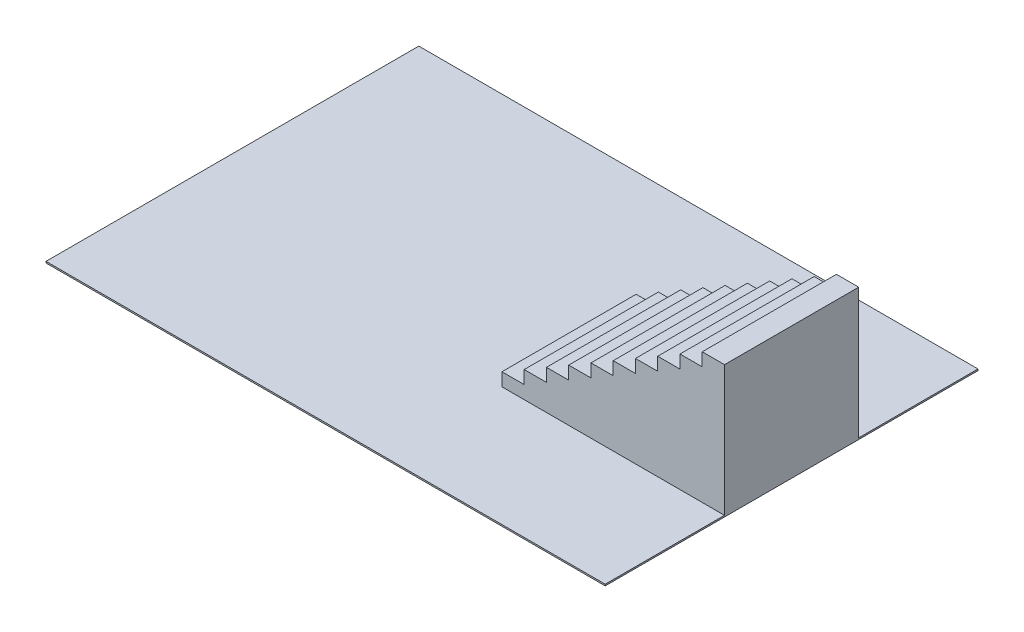
from build123d import *

# Parameters (mm, degrees)
SKETCH1_W           = 1905
SKETCH1_H           = 1270
BOSS_EXTRUDE1_DEPTH = 5.08
BOSS_EXTRUDE2_DEPTH = 228.6


with BuildPart() as part:
    # Sketch1 → Boss-Extrude1 (new body)
    with BuildSketch(Plane(origin=(0, 0, 0), x_dir=(1, 0, 0), z_dir=(0, 1, 0))):
        Rectangle(SKETCH1_W, SKETCH1_H)
    extrude(amount=BOSS_EXTRUDE1_DEPTH)

    # Sketch2 → Boss-Extrude2 (add, symmetric)
    with BuildSketch(Plane.XY):
        Polygon((194.31, 5.08), (194.31, 49.53), (270.129, 49.53), (270.129, 93.98), (345.948, 93.98), (345.948, 138.43), (421.767, 138.43), (421.767, 182.88), (497.586, 182.88), (497.586, 227.33), (573.405, 227.33), (573.405, 271.78), (649.224, 271.78), (649.224, 316.23), (725.043, 316.23), (725.043, 360.68), (800.862, 360.68), (800.862, 405.13), (876.681, 405.13), (876.681, 449.58), (952.5, 449.58), (952.5, 5.08), align=None)
    extrude(amount=BOSS_EXTRUDE2_DEPTH, both=True)


solid = part.part
